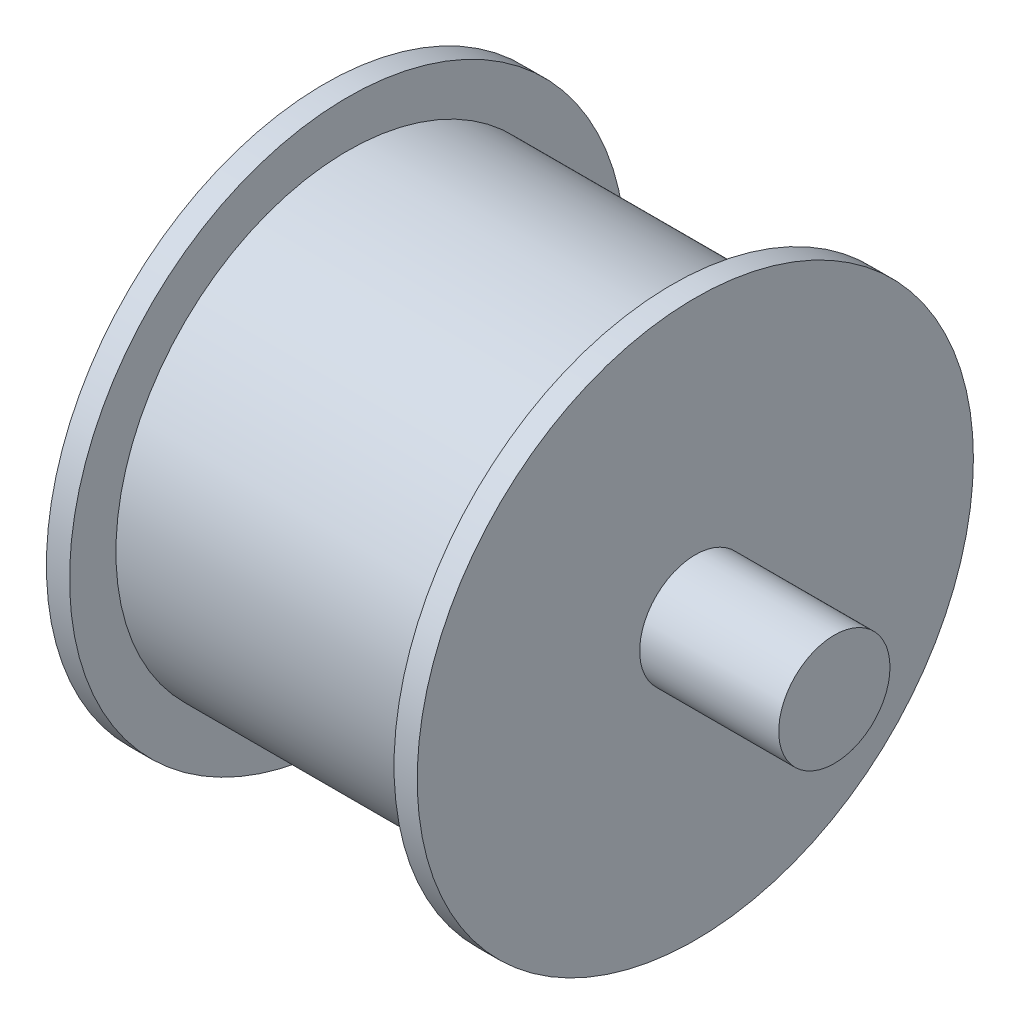
from build123d import *

# Parameters (mm, degrees)
SKETCH3_R           = 6
BOSS_EXTRUDE1_DEPTH = 15
SKETCH4_R           = 30
BOSS_EXTRUDE2_DEPTH = 2.5
BOSS_EXTRUDE3_START = 2.5
SKETCH4_3_R         = 25
BOSS_EXTRUDE3_DEPTH = 17.5


with BuildPart() as part:
    # Sketch3 → Boss-Extrude1 (new body)
    with BuildSketch(Plane(origin=(0, 0, 0), x_dir=(0, 0, -1), z_dir=(1, 0, 0))):
        Circle(SKETCH3_R)
    boss_extrude1 = extrude(amount=-BOSS_EXTRUDE1_DEPTH)

    # Sketch4 → Boss-Extrude2 (add)
    with BuildSketch(Plane(origin=(0, 0, 0), x_dir=(0, 0, -1), z_dir=(1, 0, 0))):
        Circle(SKETCH4_R)
    boss_extrude2 = extrude(amount=BOSS_EXTRUDE2_DEPTH)

    # Sketch4_3 → Boss-Extrude3 (add)
    with BuildSketch(Plane(origin=(0, 0, 0), x_dir=(0, 0, -1), z_dir=(1, 0, 0)).offset(BOSS_EXTRUDE3_START)):
        Circle(SKETCH4_3_R)
    boss_extrude3 = extrude(amount=BOSS_EXTRUDE3_DEPTH)

    # Mirror1: Boss-Extrude3 across plane
    add(boss_extrude3.mirror(Plane(origin=(20, 0, 0), x_dir=(0, 0, 1), z_dir=(1, 0, 0))))

    # Mirror2: Boss-Extrude2 across plane
    add(boss_extrude2.mirror(Plane(origin=(20, 0, 0), x_dir=(0, 0, 1), z_dir=(1, 0, 0))))

    # Mirror3: Boss-Extrude1 across plane
    add(boss_extrude1.mirror(Plane(origin=(20, 0, 0), x_dir=(0, 0, 1), z_dir=(1, 0, 0))))


solid = part.part
